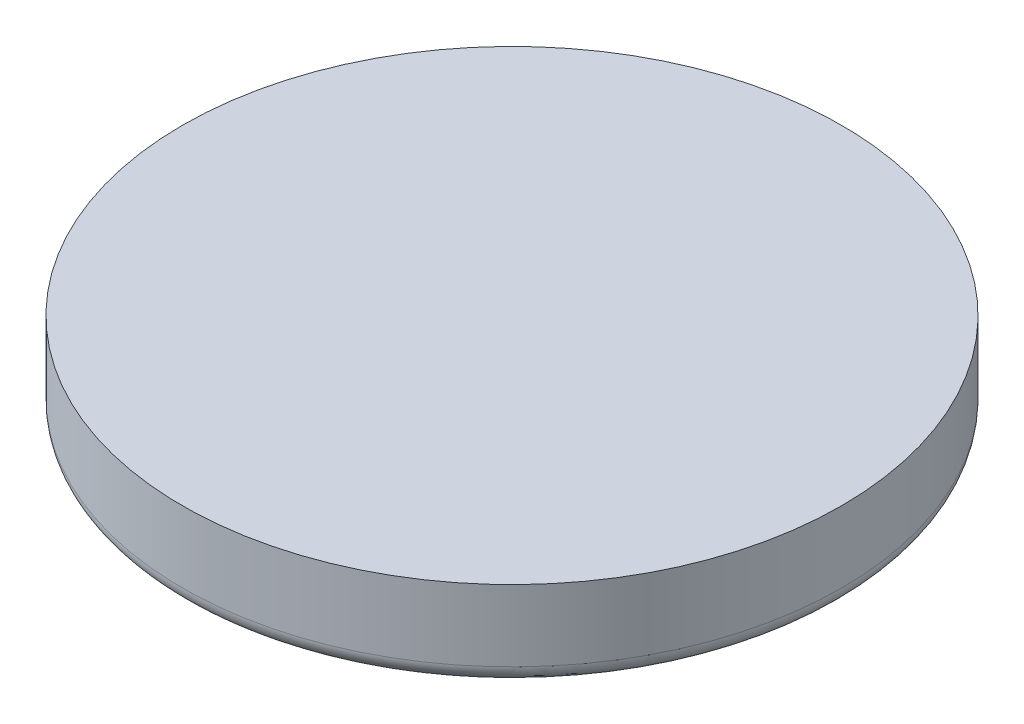
from build123d import *


with BuildPart() as part:
    # Esquisse1 → Révolution1 (revolve)
    with BuildSketch(Plane.XY):
        with BuildLine():
            Line((0, 3), (35, 3))
            ThreePointArc((35, 3), (36.414213562, 3.585786438), (37, 5))
            Line((37, 5), (37, 13))
            Line((37, 13), (0, 13))
            Line((0, 13), (0, 3))
        make_face()
    revolve(axis=Axis((0, 13, 0), (0, -1, 0)))


solid = part.part
